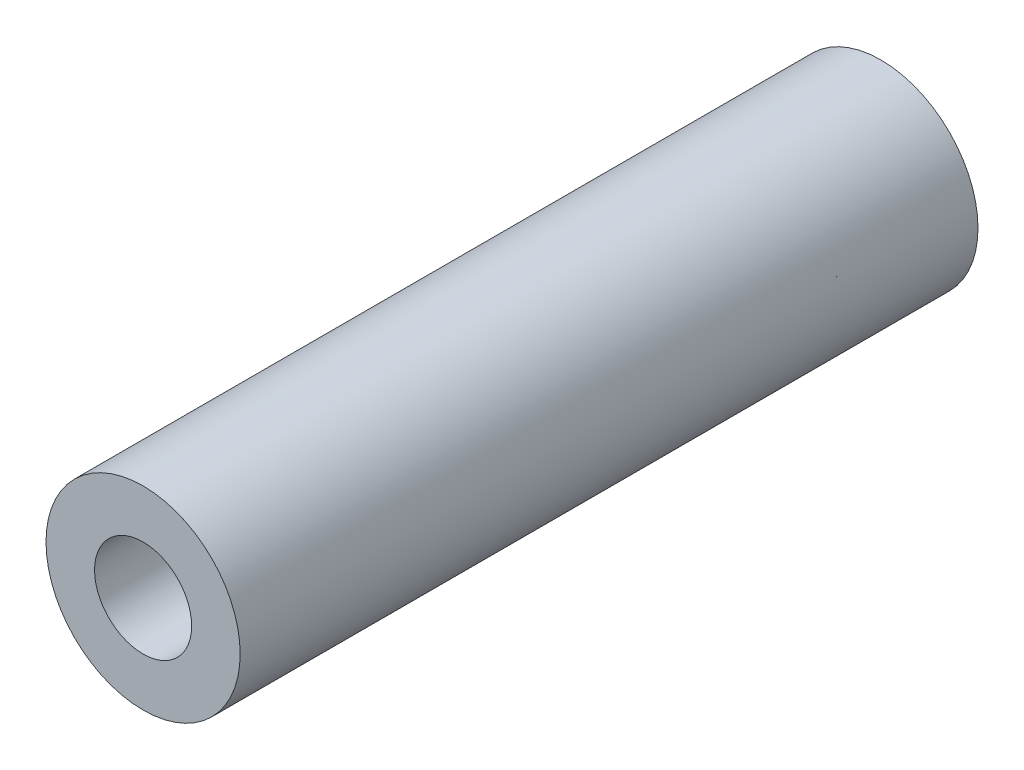
from build123d import *

# Parameters (mm, degrees)
SKETCH_1_R               = 2.5
EXTRUDE_1_DEPTH          = 9.5
M3X0_5_1_D               = 2.5
M3X0_5_1_DEPTH           = 8.5
M3X0_5_1_TIP             = 0.751075774
M3X0_5_1_ON_FACE_2_D     = 2.5
M3X0_5_1_ON_FACE_2_DEPTH = 8.5
M3X0_5_1_ON_FACE_2_TIP   = 0.751075774
SKETCH_3_R               = 1.25
CUT_EXTRUDE_1_DEPTH      = 19


with BuildPart() as part:
    # ｽｹｯﾁ1 → ﾎﾞｽ - 押し出し1 (new body, symmetric)
    with BuildSketch(Plane.XY):
        Circle(SKETCH_1_R)
    extrude(amount=EXTRUDE_1_DEPTH, both=True)

    # M3x0.5 ねじ穴1
    with Locations(Plane.XY.offset(9.5)):
        with Locations((0, 0)):
            Hole(M3X0_5_1_D / 2, depth=M3X0_5_1_DEPTH)
            with Locations((0, 0, -(M3X0_5_1_DEPTH + M3X0_5_1_TIP / 2))):  # 118° drill point
                Cone(0, M3X0_5_1_D / 2, M3X0_5_1_TIP, mode=Mode.SUBTRACT)

    # M3x0.5 ねじ穴1 on face 2
    with Locations(Plane(origin=(0, 0, -9.5), x_dir=(-1, 0, 0), z_dir=(0, 0, -1))):
        with Locations((0, 0)):
            Hole(M3X0_5_1_ON_FACE_2_D / 2, depth=M3X0_5_1_ON_FACE_2_DEPTH)
            with Locations((0, 0, -(M3X0_5_1_ON_FACE_2_DEPTH + M3X0_5_1_ON_FACE_2_TIP / 2))):  # 118° drill point
                Cone(0, M3X0_5_1_ON_FACE_2_D / 2, M3X0_5_1_ON_FACE_2_TIP, mode=Mode.SUBTRACT)

    # ｽｹｯﾁ3 → ｶｯﾄ - 押し出し1 (cut)
    with BuildSketch(Plane(origin=(0, 0, -9.5), x_dir=(-1, 0, 0), z_dir=(0, 0, -1))):
        Circle(SKETCH_3_R)
    extrude(amount=-CUT_EXTRUDE_1_DEPTH, mode=Mode.SUBTRACT)


solid = part.part
